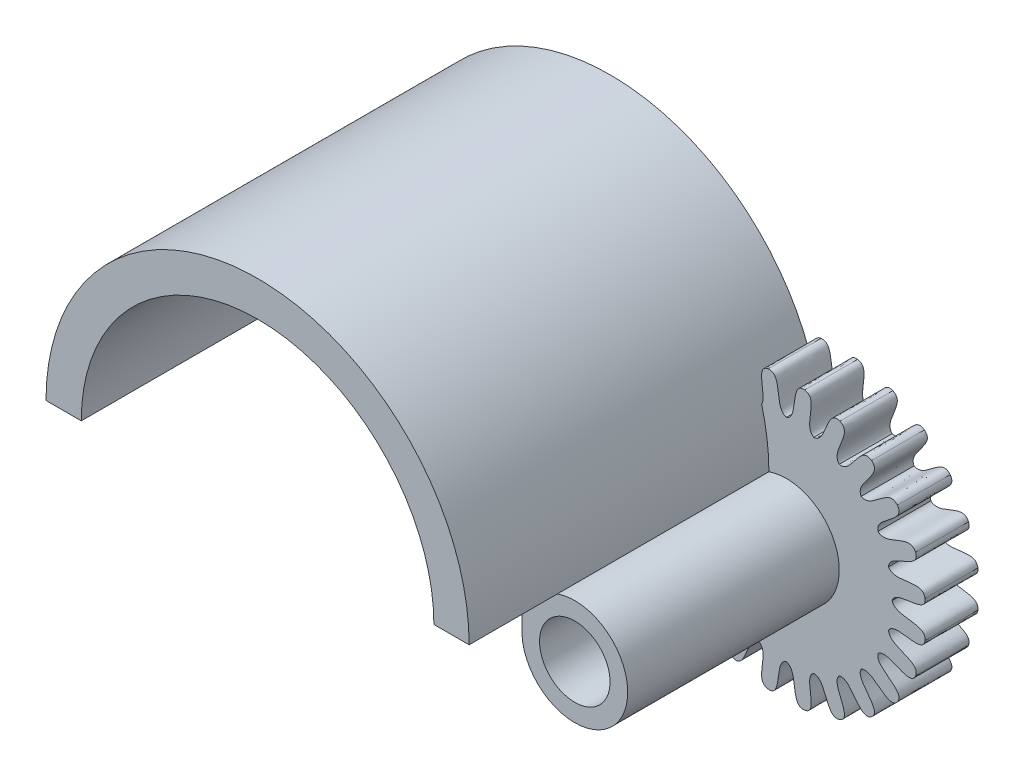
from build123d import *

# Parameters (mm, degrees)
BOSS_EXTRUDE1_DEPTH = 20
SKETCH5_R           = 2
BOSS_EXTRUDE4_DEPTH = 15
SKETCH7_R           = 2
BOSS_EXTRUDE5_DEPTH = 3


with BuildPart() as part:
    # Sketch1 → Boss-Extrude1 (new body)
    with BuildSketch(Plane.XY):
        with BuildLine():
            Line((-12, 0), (-10, 0))
            ThreePointArc((-10, 0), (0, 10), (10, 0))
            Line((10, 0), (12, 0))
            ThreePointArc((12, 0), (11.984990613, 0.6), (11.94, 1.198499061))
            ThreePointArc((11.94, 1.198499061), (11.893303563, 1.596662255), (11.833333333, 1.993043457))
            ThreePointArc((11.833333333, 1.993043457), (-1, 11.958260743), (-12, 0))
        make_face()
    extrude(amount=BOSS_EXTRUDE1_DEPTH)

    # Sketch5 → Boss-Extrude4 (add)
    with BuildSketch(Plane(origin=(0, 0, 0), x_dir=(-1, 0, 0), z_dir=(0, 0, -1))):
        with BuildLine():
            Line((-10, 0), (-10, -2.609078175))
            ThreePointArc((-10, -2.609078175), (-15.372704459, -4.656454335), (-12, 0))
            Line((-12, 0), (-10, 0))
        make_face()
        with Locations((-12.991756156, -2.831328262)):
            Circle(SKETCH5_R, mode=Mode.SUBTRACT)
    extrude(amount=-BOSS_EXTRUDE4_DEPTH)

    # Sketch7 → Boss-Extrude5 (add)
    with BuildSketch(Plane(origin=(0, 0, 0), x_dir=(-1, 0, 0), z_dir=(0, 0, -1))):
        with BuildLine():
            add(Edge.make_bspline(
                [(-12.991756156, 3.168671738), (-13.71220328, 3.366255248), (-13.171116969, 5.138806675), (-14.027032337, 5.032375043)],
                knots=[0, 0, 0, 0, 1, 1, 1, 1], degree=3))
            add(Edge.make_bspline(
                [(-14.544670427, 2.964226696), (-13.899910319, 3.341543148), (-14.881329629, 4.913652906), (-14.027032337, 5.032375043)],
                knots=[0, 0, 0, 0, 1, 1, 1, 1], degree=3))
            add(Edge.make_bspline(
                [(-14.544670427, 2.964226696), (-15.291707286, 2.968612275), (-15.227828111, 4.820808918), (-16.027032337, 4.496476658)],
                knots=[0, 0, 0, 0, 1, 1, 1, 1], degree=3))
            add(Edge.make_bspline(
                [(-15.991756156, 2.364824161), (-15.4666224, 2.896160062), (-16.821492605, 4.160691471), (-16.027032337, 4.496476658)],
                knots=[0, 0, 0, 0, 1, 1, 1, 1], degree=3))
            add(Edge.make_bspline(
                [(-15.991756156, 2.364824161), (-16.714473423, 2.175712938), (-17.132154645, 3.981330659), (-17.820183281, 3.461200478)],
                knots=[0, 0, 0, 0, 1, 1, 1, 1], degree=3))
            add(Edge.make_bspline(
                [(-17.234396843, 1.411312425), (-16.864676436, 2.060458112), (-18.50066537, 2.931235445), (-17.820183281, 3.461200478)],
                knots=[0, 0, 0, 0, 1, 1, 1, 1], degree=3))
            add(Edge.make_bspline(
                [(-17.234396843, 1.411312425), (-17.88354253, 1.041592018), (-18.754319864, 2.677580952), (-19.284284896, 1.997098863)],
                knots=[0, 0, 0, 0, 1, 1, 1, 1], degree=3))
            add(Edge.make_bspline(
                [(-18.187908579, 0.168671738), (-17.998797356, 0.891389005), (-19.804415077, 1.309070226), (-19.284284896, 1.997098863)],
                knots=[0, 0, 0, 0, 1, 1, 1, 1], degree=3))
            add(Edge.make_bspline(
                [(-18.187908579, 0.168671738), (-18.71924448, -0.356462018), (-19.983775889, 0.998408186), (-20.319561077, 0.203947919)],
                knots=[0, 0, 0, 0, 1, 1, 1, 1], degree=3))
            add(Edge.make_bspline(
                [(-18.787311114, -1.278413991), (-18.791696693, -0.531377132), (-20.643893336, -0.595256307), (-20.319561077, 0.203947919)],
                knots=[0, 0, 0, 0, 1, 1, 1, 1], degree=3))
            add(Edge.make_bspline(
                [(-18.787311114, -1.278413991), (-19.164627566, -1.923174099), (-20.736737325, -0.941754789), (-20.855459462, -1.796052081)],
                knots=[0, 0, 0, 0, 1, 1, 1, 1], degree=3))
            add(Edge.make_bspline(
                [(-18.991756156, -2.831328262), (-19.189339666, -2.110881138), (-20.961891093, -2.651967449), (-20.855459462, -1.796052081)],
                knots=[0, 0, 0, 0, 1, 1, 1, 1], degree=3))
            add(Edge.make_bspline(
                [(-18.991756156, -2.831328262), (-19.189339666, -3.551775386), (-20.961891093, -3.010689074), (-20.855459462, -3.866604442)],
                knots=[0, 0, 0, 0, 1, 1, 1, 1], degree=3))
            add(Edge.make_bspline(
                [(-18.787311114, -4.384242532), (-19.164627566, -3.739482424), (-20.736737325, -4.720901735), (-20.855459462, -3.866604442)],
                knots=[0, 0, 0, 0, 1, 1, 1, 1], degree=3))
            add(Edge.make_bspline(
                [(-18.787311114, -4.384242532), (-18.791696693, -5.131279391), (-20.643893336, -5.067400216), (-20.319561077, -5.866604442)],
                knots=[0, 0, 0, 0, 1, 1, 1, 1], degree=3))
            add(Edge.make_bspline(
                [(-18.187908579, -5.831328262), (-18.71924448, -5.306194505), (-19.983775889, -6.66106471), (-20.319561077, -5.866604442)],
                knots=[0, 0, 0, 0, 1, 1, 1, 1], degree=3))
            add(Edge.make_bspline(
                [(-18.187908579, -5.831328262), (-17.998797356, -6.554045528), (-19.804415077, -6.97172675), (-19.284284896, -7.659755387)],
                knots=[0, 0, 0, 0, 1, 1, 1, 1], degree=3))
            add(Edge.make_bspline(
                [(-17.234396843, -7.073968949), (-17.88354253, -6.704248542), (-18.754319864, -8.340237476), (-19.284284896, -7.659755387)],
                knots=[0, 0, 0, 0, 1, 1, 1, 1], degree=3))
            add(Edge.make_bspline(
                [(-17.234396843, -7.073968949), (-16.864676436, -7.723114636), (-18.50066537, -8.593891969), (-17.820183281, -9.123857002)],
                knots=[0, 0, 0, 0, 1, 1, 1, 1], degree=3))
            add(Edge.make_bspline(
                [(-15.991756156, -8.027480685), (-16.714473423, -7.838369462), (-17.132154645, -9.643987182), (-17.820183281, -9.123857002)],
                knots=[0, 0, 0, 0, 1, 1, 1, 1], degree=3))
            add(Edge.make_bspline(
                [(-15.991756156, -8.027480685), (-15.4666224, -8.558816586), (-16.821492605, -9.823347995), (-16.027032337, -10.159133182)],
                knots=[0, 0, 0, 0, 1, 1, 1, 1], degree=3))
            add(Edge.make_bspline(
                [(-14.544670427, -8.62688322), (-15.291707286, -8.631268798), (-15.227828111, -10.483465442), (-16.027032337, -10.159133182)],
                knots=[0, 0, 0, 0, 1, 1, 1, 1], degree=3))
            add(Edge.make_bspline(
                [(-14.544670427, -8.62688322), (-13.899910319, -9.004199672), (-14.881329629, -10.57630943), (-14.027032337, -10.695031567)],
                knots=[0, 0, 0, 0, 1, 1, 1, 1], degree=3))
            add(Edge.make_bspline(
                [(-12.991756156, -8.831328262), (-13.71220328, -9.028911772), (-13.171116969, -10.801463198), (-14.027032337, -10.695031567)],
                knots=[0, 0, 0, 0, 1, 1, 1, 1], degree=3))
            add(Edge.make_bspline(
                [(-12.991756156, -8.831328262), (-12.271309032, -9.028911772), (-12.812395344, -10.801463198), (-11.956479976, -10.695031567)],
                knots=[0, 0, 0, 0, 1, 1, 1, 1], degree=3))
            add(Edge.make_bspline(
                [(-11.438841886, -8.62688322), (-12.083601994, -9.004199672), (-11.102182684, -10.57630943), (-11.956479976, -10.695031567)],
                knots=[0, 0, 0, 0, 1, 1, 1, 1], degree=3))
            add(Edge.make_bspline(
                [(-11.438841886, -8.62688322), (-10.691805027, -8.631268798), (-10.755684202, -10.483465442), (-9.956479976, -10.159133182)],
                knots=[0, 0, 0, 0, 1, 1, 1, 1], degree=3))
            add(Edge.make_bspline(
                [(-9.991756156, -8.027480685), (-10.516889913, -8.558816586), (-9.162019708, -9.823347995), (-9.956479976, -10.159133182)],
                knots=[0, 0, 0, 0, 1, 1, 1, 1], degree=3))
            add(Edge.make_bspline(
                [(-9.991756156, -8.027480685), (-9.26903889, -7.838369462), (-8.851357668, -9.643987182), (-8.163329032, -9.123857002)],
                knots=[0, 0, 0, 0, 1, 1, 1, 1], degree=3))
            add(Edge.make_bspline(
                [(-8.749115469, -7.073968949), (-9.118835876, -7.723114636), (-7.482846943, -8.593891969), (-8.163329032, -9.123857002)],
                knots=[0, 0, 0, 0, 1, 1, 1, 1], degree=3))
            add(Edge.make_bspline(
                [(-8.749115469, -7.073968949), (-8.099969783, -6.704248542), (-7.229192449, -8.340237476), (-6.699227416, -7.659755387)],
                knots=[0, 0, 0, 0, 1, 1, 1, 1], degree=3))
            add(Edge.make_bspline(
                [(-7.795603734, -5.831328262), (-7.984714956, -6.554045528), (-6.179097236, -6.97172675), (-6.699227416, -7.659755387)],
                knots=[0, 0, 0, 0, 1, 1, 1, 1], degree=3))
            add(Edge.make_bspline(
                [(-7.795603734, -5.831328262), (-7.264267833, -5.306194505), (-5.999736424, -6.66106471), (-5.663951236, -5.866604442)],
                knots=[0, 0, 0, 0, 1, 1, 1, 1], degree=3))
            add(Edge.make_bspline(
                [(-7.196201199, -4.384242532), (-7.19181562, -5.131279391), (-5.339618976, -5.067400216), (-5.663951236, -5.866604442)],
                knots=[0, 0, 0, 0, 1, 1, 1, 1], degree=3))
            add(Edge.make_bspline(
                [(-7.196201199, -4.384242532), (-6.818884747, -3.739482424), (-5.246774988, -4.720901735), (-5.128052851, -3.866604442)],
                knots=[0, 0, 0, 0, 1, 1, 1, 1], degree=3))
            add(Edge.make_bspline(
                [(-6.991756156, -2.831328262), (-6.794172646, -3.551775386), (-5.02162122, -3.010689074), (-5.128052851, -3.866604442)],
                knots=[0, 0, 0, 0, 1, 1, 1, 1], degree=3))
            add(Edge.make_bspline(
                [(-6.991756156, -2.831328262), (-6.794172646, -2.110881138), (-5.02162122, -2.651967449), (-5.128052851, -1.796052081)],
                knots=[0, 0, 0, 0, 1, 1, 1, 1], degree=3))
            add(Edge.make_bspline(
                [(-7.196201199, -1.278413991), (-6.818884747, -1.923174099), (-5.246774988, -0.941754789), (-5.128052851, -1.796052081)],
                knots=[0, 0, 0, 0, 1, 1, 1, 1], degree=3))
            add(Edge.make_bspline(
                [(-7.196201199, -1.278413991), (-7.19181562, -0.531377132), (-5.339618976, -0.595256307), (-5.663951236, 0.203947919)],
                knots=[0, 0, 0, 0, 1, 1, 1, 1], degree=3))
            add(Edge.make_bspline(
                [(-7.795603734, 0.168671738), (-7.264267833, -0.356462018), (-5.999736424, 0.998408186), (-5.663951236, 0.203947919)],
                knots=[0, 0, 0, 0, 1, 1, 1, 1], degree=3))
            add(Edge.make_bspline(
                [(-7.795603734, 0.168671738), (-7.984714956, 0.891389005), (-6.179097236, 1.309070226), (-6.699227416, 1.997098863)],
                knots=[0, 0, 0, 0, 1, 1, 1, 1], degree=3))
            add(Edge.make_bspline(
                [(-8.749115469, 1.411312425), (-8.099969783, 1.041592018), (-7.229192449, 2.677580952), (-6.699227416, 1.997098863)],
                knots=[0, 0, 0, 0, 1, 1, 1, 1], degree=3))
            add(Edge.make_bspline(
                [(-8.749115469, 1.411312425), (-9.118835876, 2.060458112), (-7.482846943, 2.931235445), (-8.163329032, 3.461200478)],
                knots=[0, 0, 0, 0, 1, 1, 1, 1], degree=3))
            add(Edge.make_bspline(
                [(-9.991756156, 2.364824161), (-9.26903889, 2.175712938), (-8.851357668, 3.981330659), (-8.163329032, 3.461200478)],
                knots=[0, 0, 0, 0, 1, 1, 1, 1], degree=3))
            ThreePointArc((-9.991756156, 2.364824161), (-10.695655562, 2.711948933), (-11.438841886, 2.964226696))
            add(Edge.make_bspline(
                [(-11.438841886, 2.964226696), (-12.083601994, 3.341543148), (-11.102182684, 4.913652906), (-11.956479976, 5.032375043)],
                knots=[0, 0, 0, 0, 1, 1, 1, 1], degree=3))
            add(Edge.make_bspline(
                [(-12.991756156, 3.168671738), (-12.271309032, 3.366255248), (-12.812395344, 5.138806675), (-11.956479976, 5.032375043)],
                knots=[0, 0, 0, 0, 1, 1, 1, 1], degree=3))
        make_face()
        with Locations((-12.991756156, -2.831328262)):
            Circle(SKETCH7_R, mode=Mode.SUBTRACT)
    extrude(amount=-BOSS_EXTRUDE5_DEPTH)


solid = part.part
